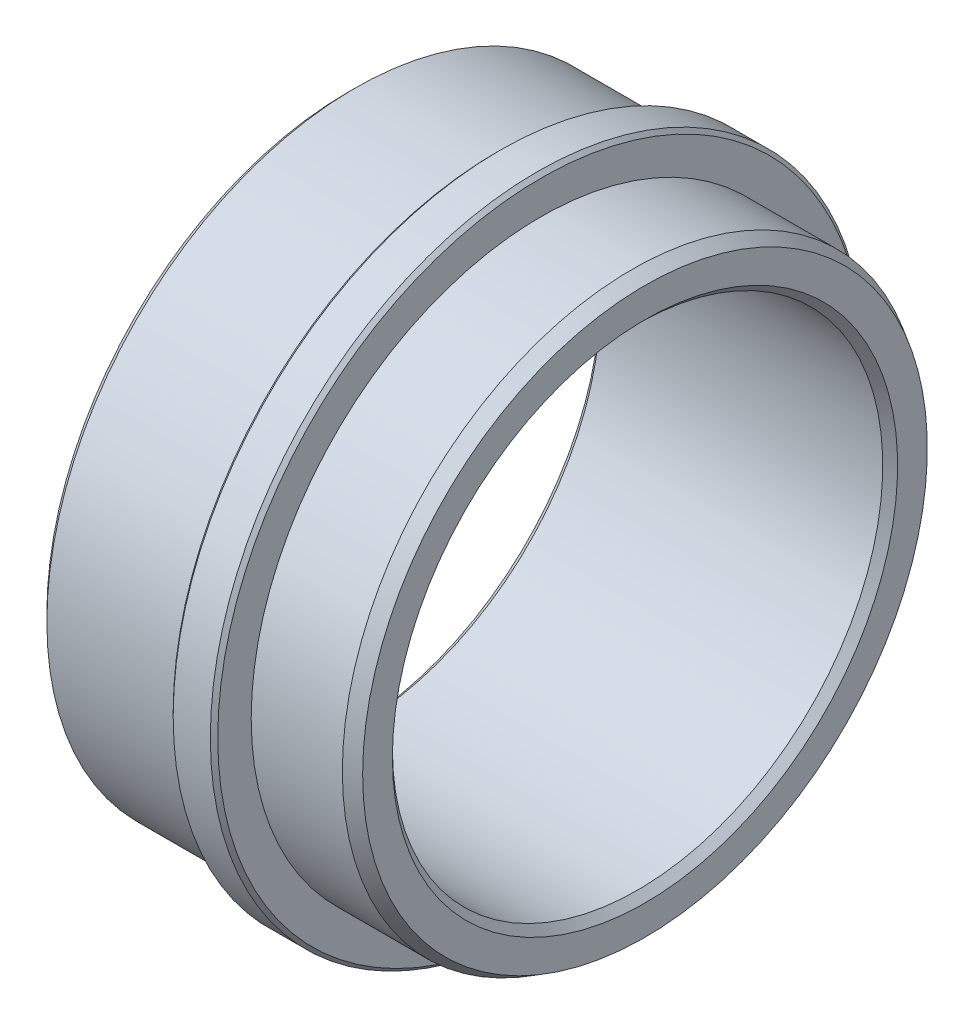
from build123d import *


with BuildPart() as part:
    # Esquisse1 → Révolution1 (revolve)
    with BuildSketch(Plane.XY, mode=Mode.PRIVATE) as r_volution1_sk:
        Polygon((-13.941052428, 17), (-13.941052428, 20.25), (-13.441052428, 20.75), (-3.941052428, 20.75), (-3.941052428, 21.75), (-3.691052428, 22), (-1.191052428, 22), (-0.941052428, 21.75), (-0.941052428, 19.5), (5.192922168, 19.5), (6.058947572, 19), (6.058947572, 17), (5.558947572, 16.5), (-13.441052428, 16.5), align=None)
    revolve(r_volution1_sk.sketch.rotate(Axis((0, 0, 0), (1, 0, 0)), 90), axis=Axis((0, 0, 0), (1, 0, 0)))  # turned: the seam where the file's is


solid = part.part
